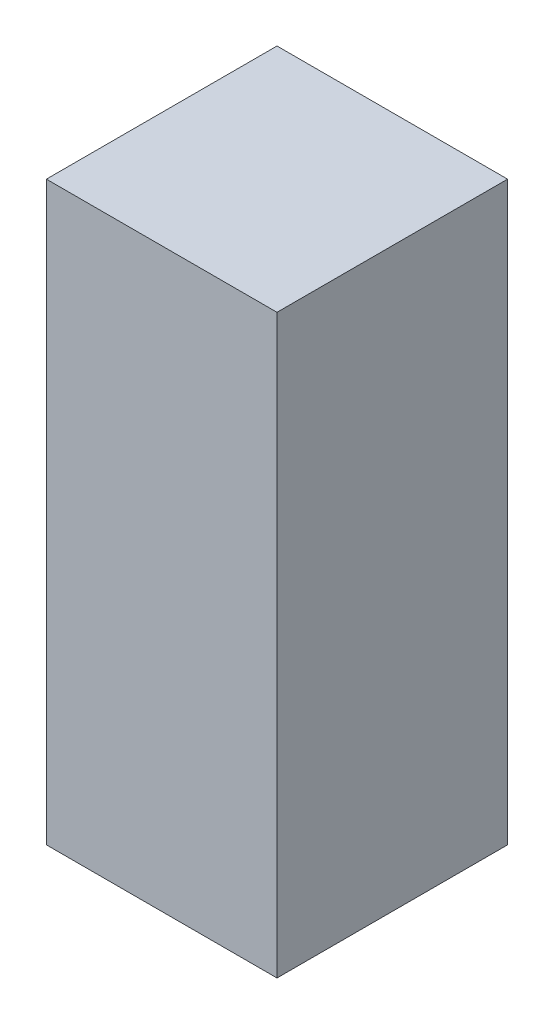
from build123d import *

# Parameters (mm, degrees)
SKETCH1_W           = 20.32
SKETCH1_H           = 20.32
BOSS_EXTRUDE1_DEPTH = 50.8


with BuildPart() as part:
    # Sketch1 → Boss-Extrude1 (new body)
    with BuildSketch(Plane(origin=(0, 0, 0), x_dir=(1, 0, 0), z_dir=(0, 1, 0))):
        with Locations((10.16, 10.16)):
            Rectangle(SKETCH1_W, SKETCH1_H)
    extrude(amount=BOSS_EXTRUDE1_DEPTH)


solid = part.part
